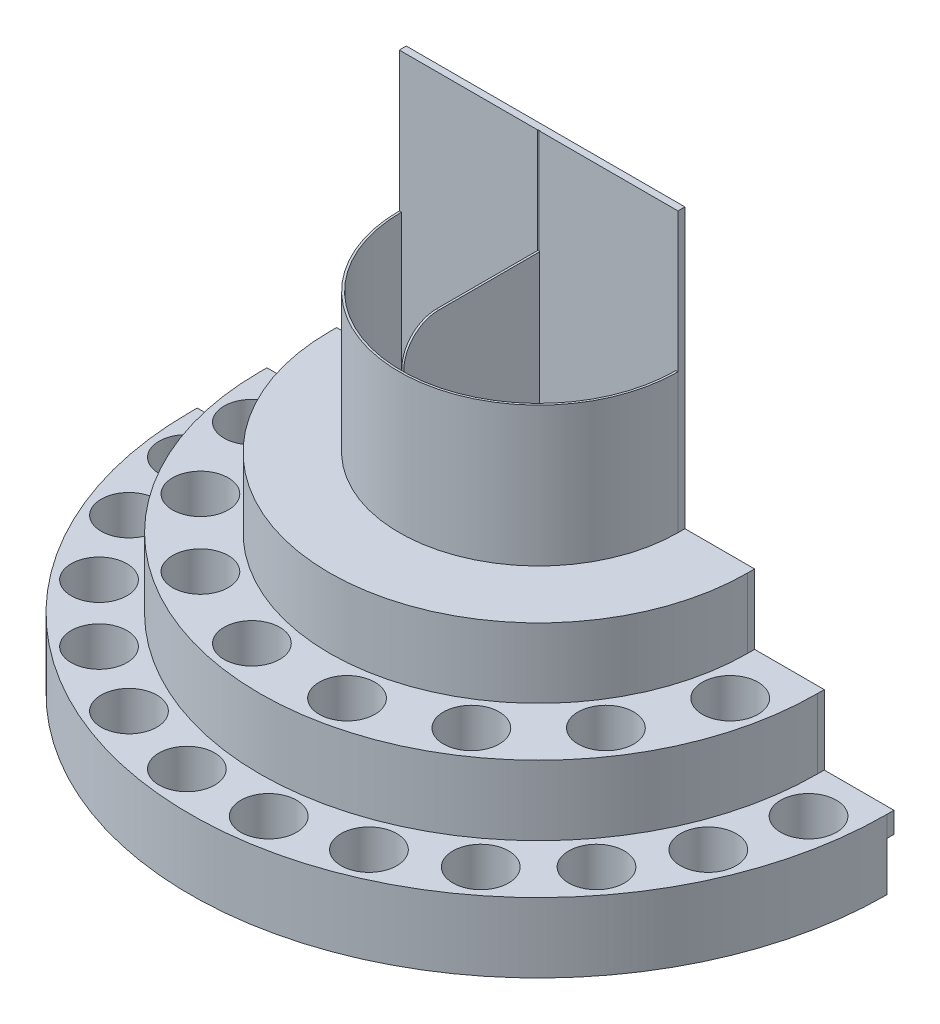
from build123d import *

# Parameters (mm, degrees)
EXTRUSION1_DEPTH = 100
EXTRUSION2_DEPTH = 100
EXTRUSION3_DEPTH = 100
EXTRUSION4_DEPTH = 200
EXTRUSION5_DEPTH = 10
ESQUISSE6_R      = 40
EXTRUSION6_DEPTH = 300
ESQUISSE7_W      = 3
ESQUISSE7_H      = 195
EXTRUSION8_DEPTH = 250
CONG_1_R         = 50
ESQUISSE8_W      = 3
ESQUISSE8_H      = 150
EXTRUSION9_DEPTH = 0.5


with BuildPart() as part:
    # Esquisse1 → Extrusion1 (new body)
    with BuildSketch(Plane(origin=(0, 0, 0), x_dir=(1, 0, 0), z_dir=(0, 1, 0))):
        with BuildLine():
            Line((-500, 0), (0, 0))
            Line((0, 0), (500, 0))
            ThreePointArc((500, 0), (0, -500), (-500, 0))
        make_face()
    extrude(amount=EXTRUSION1_DEPTH)

    # Esquisse2 → Extrusion2 (add)
    with BuildSketch(Plane(origin=(0, 100, 0), x_dir=(-1, 0, 0), z_dir=(0, 1, 0))):
        with BuildLine():
            Line((400, 0), (-400, 0))
            ThreePointArc((-400, 0), (0, 400), (400, 0))
        make_face()
    extrude(amount=EXTRUSION2_DEPTH)

    # Esquisse3 → Extrusion3 (add)
    with BuildSketch(Plane(origin=(0, 200, 0), x_dir=(-1, 0, 0), z_dir=(0, 1, 0))):
        with BuildLine():
            Line((300, 0), (-300, 0))
            ThreePointArc((-300, 0), (0, 300), (300, 0))
        make_face()
    extrude(amount=EXTRUSION3_DEPTH)

    # Esquisse4 → Extrusion4 (add)
    with BuildSketch(Plane(origin=(0, 300, 0), x_dir=(-1, 0, 0), z_dir=(0, 1, 0))):
        with BuildLine():
            Line((200, 0), (197, 0))
            ThreePointArc((197, 0), (0, 197), (-197, 0))
            Line((-197, 0), (-200, 0))
            ThreePointArc((-200, 0), (0, 200), (200, 0))
        make_face()
    extrude(amount=EXTRUSION4_DEPTH)

    # Esquisse5 → Extrusion5 (add)
    with BuildSketch(Plane(origin=(0, 0, 0), x_dir=(-1, 0, 0), z_dir=(0, 0, -1))):
        with BuildLine():
            Line((200, 700), (-200, 700))
            Line((-200, 700), (-200, 300))
            Line((-200, 300), (-300, 300))
            Line((-300, 300), (-300, 200))
            Line((-300, 200), (-400, 200))
            Line((-400, 200), (-400, 100))
            Line((-400, 100), (-500, 100))
            Line((-500, 100), (-500, 70))
            Line((-500, 70), (-305.941170816, 70))
            ThreePointArc((-305.941170816, 70), (0, 250), (305.941170816, 70))
            Line((305.941170816, 70), (500, 70))
            Line((500, 70), (500, 100))
            Line((500, 100), (400, 100))
            Line((400, 100), (400, 200))
            Line((400, 200), (300, 200))
            Line((300, 200), (300, 300))
            Line((300, 300), (200, 300))
            Line((200, 300), (200, 700))
        make_face()
    extrude(amount=EXTRUSION5_DEPTH)

    # Esquisse6 → Extrusion6 (cut)
    with BuildSketch(Plane(origin=(0, 300, 0), x_dir=(1, 0, 0), z_dir=(0, 1, 0))):
        with Locations((-343.274848141, -68.281612706)):
            Circle(ESQUISSE6_R)
        with Locations((-291.014364306, -194.449581557)):
            Circle(ESQUISSE6_R)
        with Locations((-446.150187618, -58.736786499)):
            Circle(ESQUISSE6_R)
        with Locations((-415.74578963, -172.207544564)):
            Circle(ESQUISSE6_R)
        with Locations((-357.009003131, -273.942643054)):
            Circle(ESQUISSE6_R)
        with Locations((-273.942643054, -357.009003131)):
            Circle(ESQUISSE6_R)
        with Locations((-172.207544564, -415.74578963)):
            Circle(ESQUISSE6_R)
        with Locations((-58.736786499, -446.150187618)):
            Circle(ESQUISSE6_R)
        with Locations((58.736786499, -446.150187618)):
            Circle(ESQUISSE6_R)
        with Locations((172.207544564, -415.74578963)):
            Circle(ESQUISSE6_R)
        with Locations((273.942643054, -357.009003131)):
            Circle(ESQUISSE6_R)
        with Locations((357.009003131, -273.942643054)):
            Circle(ESQUISSE6_R)
        with Locations((415.74578963, -172.207544564)):
            Circle(ESQUISSE6_R)
        with Locations((446.150187618, -58.736786499)):
            Circle(ESQUISSE6_R)
        with Locations((-194.449581557, -291.014364306)):
            Circle(ESQUISSE6_R)
        with Locations((-68.281612706, -343.274848141)):
            Circle(ESQUISSE6_R)
        with Locations((68.281612706, -343.274848141)):
            Circle(ESQUISSE6_R)
        with Locations((194.449581557, -291.014364306)):
            Circle(ESQUISSE6_R)
        with Locations((291.014364306, -194.449581557)):
            Circle(ESQUISSE6_R)
        with Locations((343.274848141, -68.281612706)):
            Circle(ESQUISSE6_R)
    extrude(amount=-EXTRUSION6_DEPTH, mode=Mode.SUBTRACT)

    # Esquisse7 → Extrusion8 (add)
    with BuildSketch(Plane(origin=(0, 300, 0), x_dir=(1, 0, 0), z_dir=(0, 1, 0))):
        with Locations((0, -97.5)):
            Rectangle(ESQUISSE7_W, ESQUISSE7_H)
    extrude(amount=EXTRUSION8_DEPTH)

    # Congé1
    cong_1_edges = [part.edges().sort_by_distance(p)[0] for p in [
        (0, 550, 195),
    ]]
    fillet(cong_1_edges, radius=CONG_1_R)

    # Esquisse8 → Extrusion9 (cut)
    with BuildSketch(Plane.XY):
        with Locations((0, 625)):
            Rectangle(ESQUISSE8_W, ESQUISSE8_H)
    extrude(amount=-EXTRUSION9_DEPTH, mode=Mode.SUBTRACT)


solid = part.part
